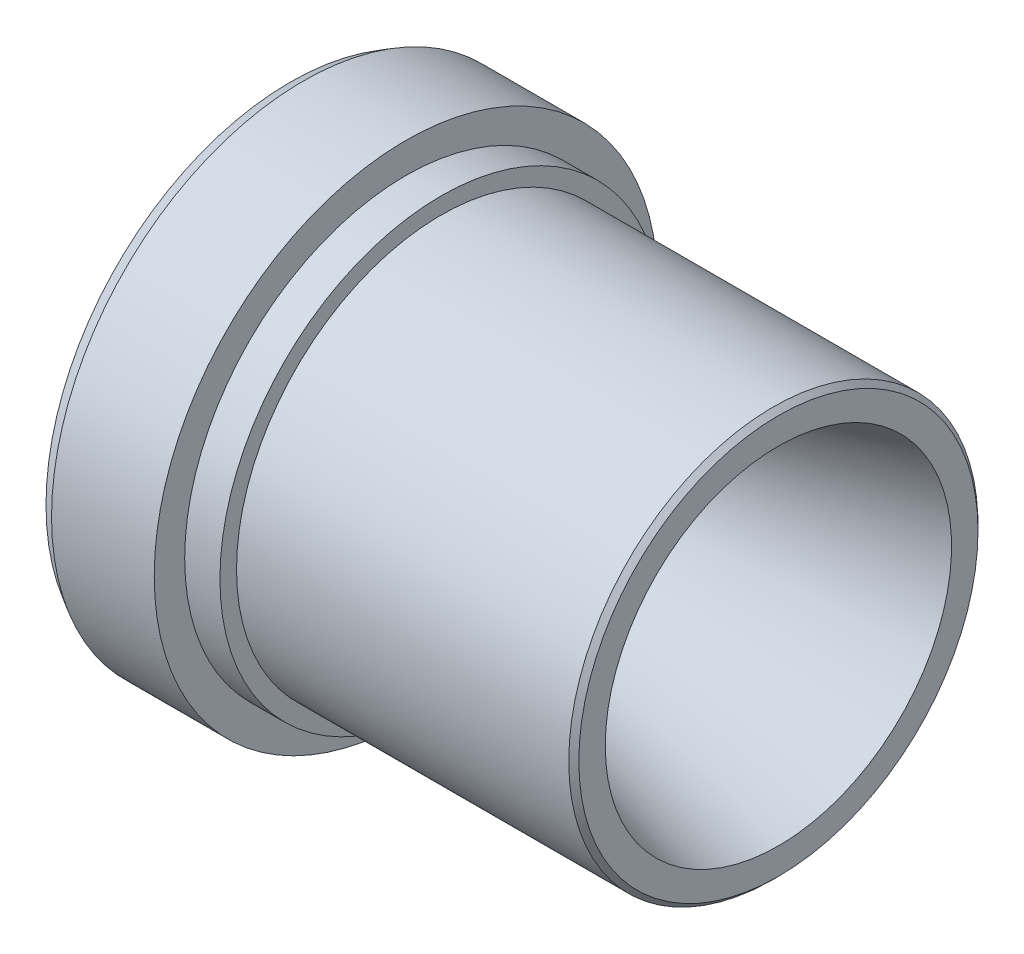
from build123d import *


with BuildPart() as part:
    # Sketch1 → Revolve1 (revolve)
    with BuildSketch(Plane.XY):
        Polygon((0, 7.9375), (0, 12.319), (0.659911358, 12.7), (5.842, 12.7), (5.842, 11.1633), (7.62, 11.1633), (7.62, 10.3251), (24.384, 10.3251), (24.638, 10.0711), (24.638, 8.7376), (5.842, 3.6957), (4.2418, 3.6957), align=None)
    revolve(axis=Axis((0, 0, 0), (1, 0, 0)))


solid = part.part
